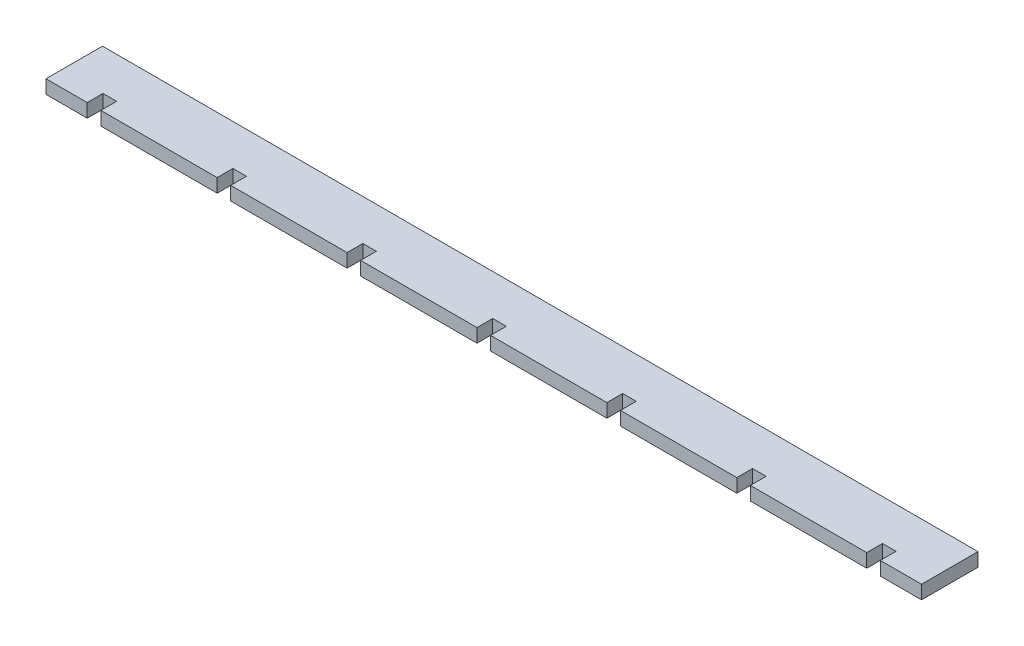
from build123d import *

# Parameters (mm, degrees)
SKETCH1_W           = 196.85
SKETCH1_H           = 12.7
BOSS_EXTRUDE1_DEPTH = 3.048
SKETCH2_W           = 3.048
SKETCH2_H           = 3.541160525
CUT_EXTRUDE1_DEPTH  = 4.048


with BuildPart() as part:
    # Sketch1 → Boss-Extrude1 (new body)
    with BuildSketch(Plane(origin=(0, 0, 0), x_dir=(1, 0, 0), z_dir=(0, 1, 0))):
        with Locations((0, 6.35)):
            Rectangle(SKETCH1_W, SKETCH1_H)
    extrude(amount=BOSS_EXTRUDE1_DEPTH)

    # Sketch2 → Cut-Extrude1 (cut, through all)
    with BuildSketch(Plane(origin=(0, 3.048, 0), x_dir=(1, 0, 0), z_dir=(0, 1, 0))):
        with Locations((87.63, 1.770580263)):
            Rectangle(SKETCH2_W, SKETCH2_H)
        with Locations((58.42, 1.770580263)):
            Rectangle(SKETCH2_W, SKETCH2_H)
        with Locations((29.21, 1.770580263)):
            Rectangle(SKETCH2_W, SKETCH2_H)
        with Locations((0, 1.770580263)):
            Rectangle(SKETCH2_W, SKETCH2_H)
        with Locations((-29.21, 1.770580263)):
            Rectangle(SKETCH2_W, SKETCH2_H)
        with Locations((-58.42, 1.770580263)):
            Rectangle(SKETCH2_W, SKETCH2_H)
        with Locations((-87.63, 1.770580263)):
            Rectangle(SKETCH2_W, SKETCH2_H)
    extrude(amount=-CUT_EXTRUDE1_DEPTH, mode=Mode.SUBTRACT)


solid = part.part
